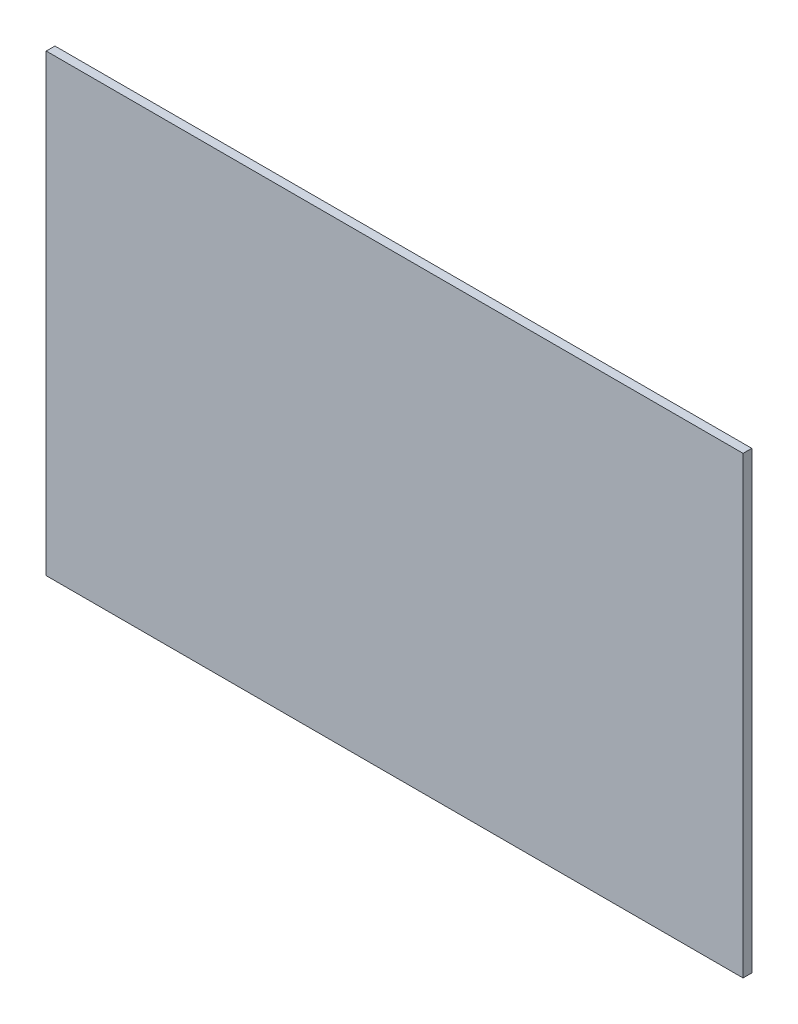
from build123d import *

# Parameters (mm, degrees)
SKETCH1_W           = 400
SKETCH1_H           = 260.8
BOSS_EXTRUDE1_DEPTH = 5


with BuildPart() as part:
    # Sketch1 → Boss-Extrude1 (new body)
    with BuildSketch(Plane.XY):
        with Locations((200, -130.4)):
            Rectangle(SKETCH1_W, SKETCH1_H)
    extrude(amount=BOSS_EXTRUDE1_DEPTH)


solid = part.part
